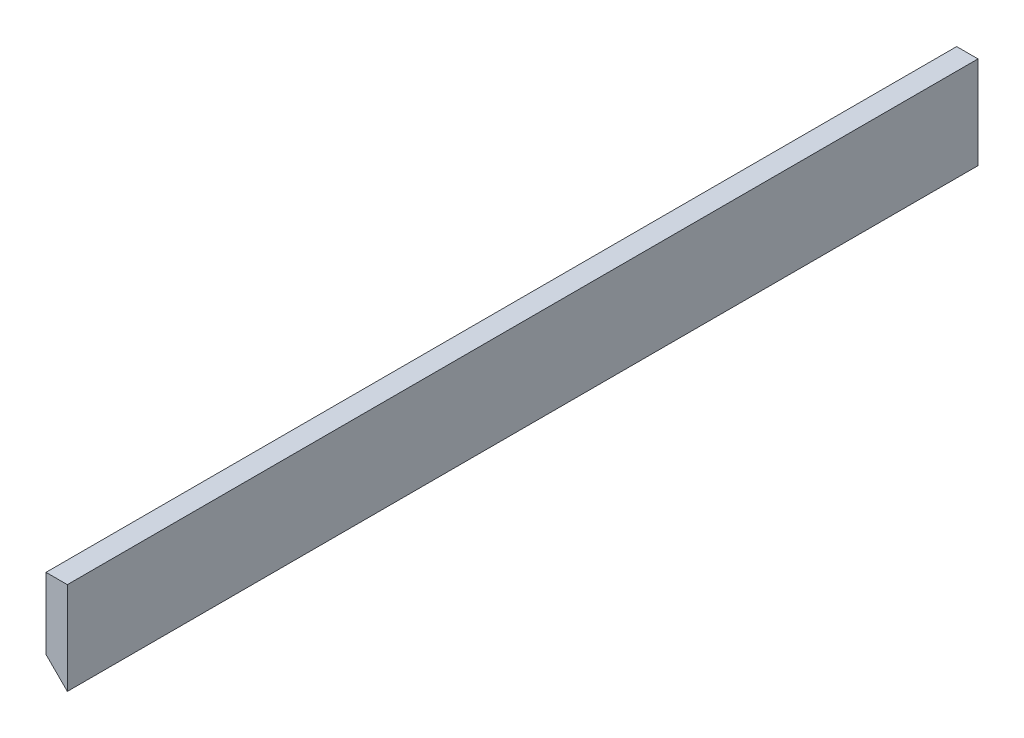
from build123d import *

# Parameters (mm, degrees)
BOSS_EXTRU_1_DEPTH = 640


with BuildPart() as part:
    # Esquisse1 → Boss.-Extru.1 (new body)
    with BuildSketch(Plane.XY):
        Polygon((0, 0), (0, 65), (-15, 65), (-15, 15), align=None)
    extrude(amount=BOSS_EXTRU_1_DEPTH)


solid = part.part
